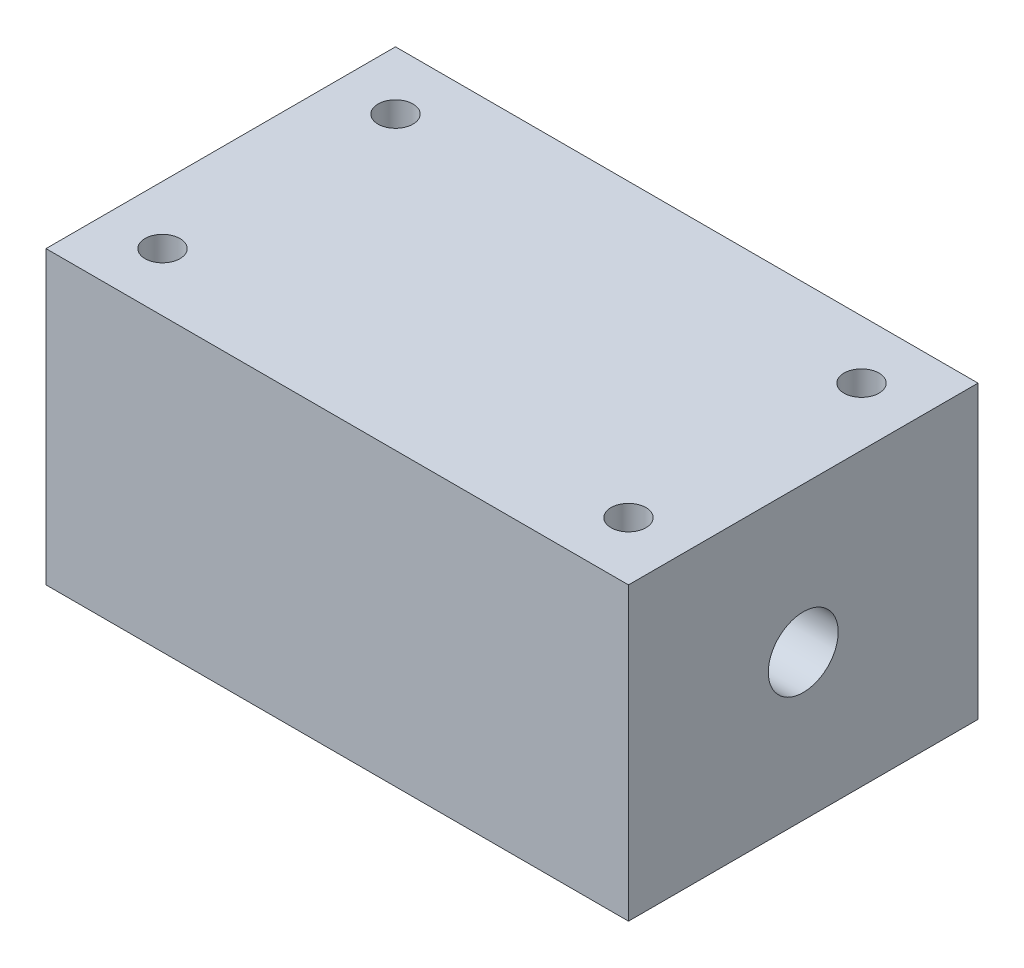
from build123d import *

# Parameters (mm, degrees)
ESQUISSE1_W             = 50
ESQUISSE1_H             = 30
ESQUISSE1_R             = 1.5
BOSS_EXTRU_1_DEPTH      = 25
ENL_V_MAT_EXTRU_1_REACH = 52
ESQUISSE2_R             = 3


with BuildPart() as part:
    # Esquisse1 → Boss.-Extru.1 (new body)
    with BuildSketch(Plane(origin=(0, 0, 0), x_dir=(1, 0, 0), z_dir=(0, 1, 0))):
        Rectangle(ESQUISSE1_W, ESQUISSE1_H)
        with Locations((-20, 10)):
            Circle(ESQUISSE1_R, mode=Mode.SUBTRACT)
        with Locations((-20, -10)):
            Circle(ESQUISSE1_R, mode=Mode.SUBTRACT)
        with Locations((20, -10)):
            Circle(ESQUISSE1_R, mode=Mode.SUBTRACT)
        with Locations((20, 10)):
            Circle(ESQUISSE1_R, mode=Mode.SUBTRACT)
    extrude(amount=BOSS_EXTRU_1_DEPTH)

    # Esquisse2 → Enlèv. mat.-Extru.1 (cut, up to next)
    with BuildSketch(Plane.ZY.offset(25), mode=Mode.PRIVATE) as enl_v_mat_extru_1_sk1:
        with Locations((0, 12.5)):
            Circle(ESQUISSE2_R)
    enl_v_mat_extru_1_tool1 = extrude(enl_v_mat_extru_1_sk1.sketch, amount=-ENL_V_MAT_EXTRU_1_REACH, mode=Mode.PRIVATE) & part.part
    add(enl_v_mat_extru_1_tool1.solids().sort_by_distance((-25, 12.5, 0))[0], mode=Mode.SUBTRACT)


solid = part.part
